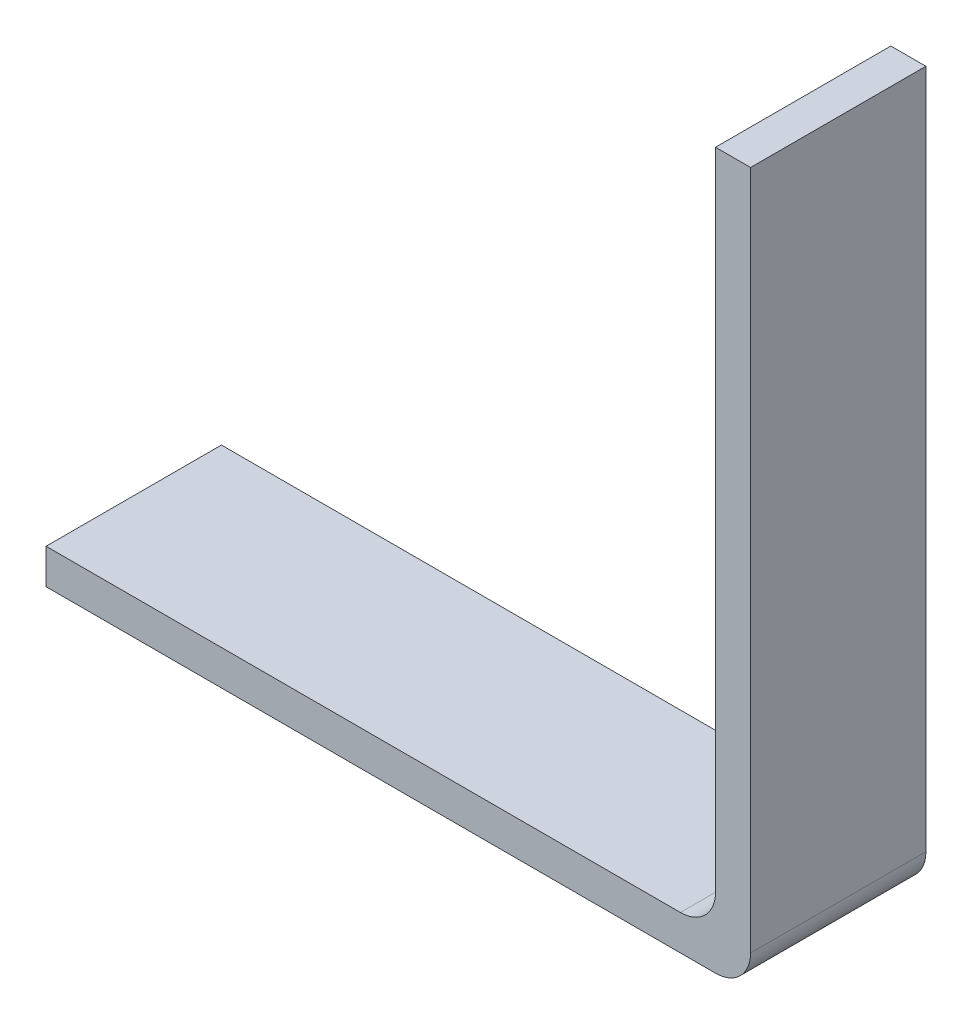
from build123d import *

# Parameters (mm, degrees)
EKSTR_ZYON_NCE2_DEPTH = 5
RADYUS1_R             = 1


with BuildPart() as part:
    # Çizim1 → Ekstrüzyon-İnce2 (new body)
    with BuildSketch(Plane.XY):
        Polygon((148.868356189, -40.017575671), (148.868356189, -60.417575671), (128.777806905, -60.417575671), (128.777806905, -59.417575671), (147.868356189, -59.417575671), (147.868356189, -40.017575671), align=None)
    extrude(amount=EKSTR_ZYON_NCE2_DEPTH)

    # Radyus1
    radyus1_edges = [part.edges().sort_by_distance(p)[0] for p in [
        (147.868356189, -59.417575671, 2.5),
        (148.868356189, -60.417575671, 2.5),
    ]]
    fillet(radyus1_edges, radius=RADYUS1_R)


solid = part.part
